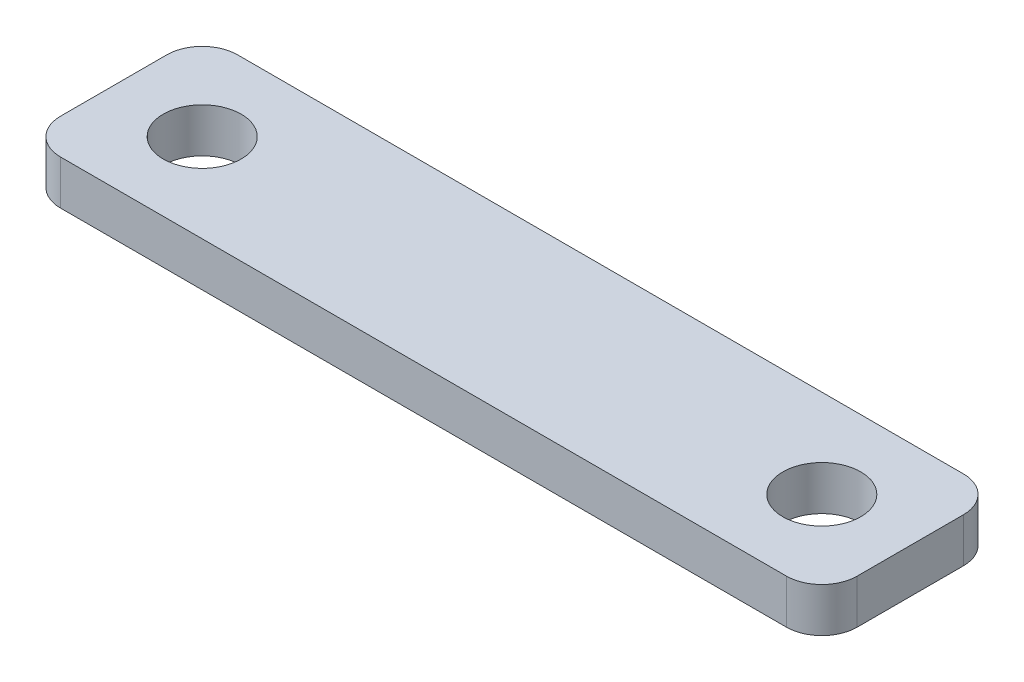
from build123d import *

# Parameters (mm, degrees)
SKETCH1_R           = 2.794
BOSS_EXTRUDE1_DEPTH = 3.175


with BuildPart() as part:
    # Sketch1 → Boss-Extrude1 (new body)
    with BuildSketch(Plane(origin=(0, 0, 0), x_dir=(1, 0, 0), z_dir=(0, 1, 0))):
        with BuildLine():
            Line((-26.035, -6.35), (26.035, -6.35))
            ThreePointArc((26.035, -6.35), (27.831051224, -5.606051224), (28.575, -3.81))
            Line((28.575, -3.81), (28.575, 3.81))
            ThreePointArc((28.575, 3.81), (27.831051224, 5.606051224), (26.035, 6.35))
            Line((26.035, 6.35), (-26.035, 6.35))
            ThreePointArc((-26.035, 6.35), (-27.831051224, 5.606051224), (-28.575, 3.81))
            Line((-28.575, 3.81), (-28.575, -3.81))
            ThreePointArc((-28.575, -3.81), (-27.831051224, -5.606051224), (-26.035, -6.35))
        make_face()
        with Locations((-22.225, 0)):
            Circle(SKETCH1_R, mode=Mode.SUBTRACT)
        with Locations((22.225, 0)):
            Circle(SKETCH1_R, mode=Mode.SUBTRACT)
    extrude(amount=BOSS_EXTRUDE1_DEPTH)


solid = part.part
